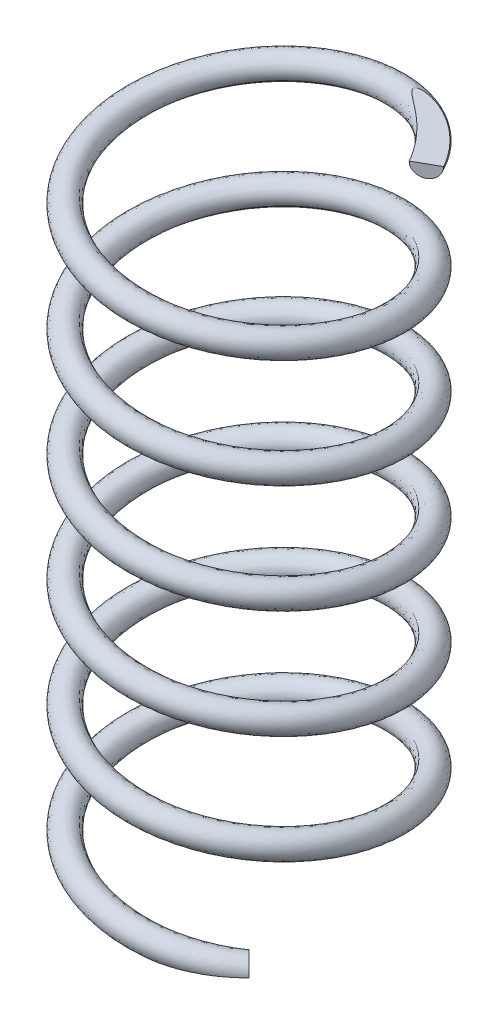
from build123d import *

# Parameters (mm, degrees)
WYCI_GNI_CIE_PO_CIE_CE1_PITCH       = 15
WYCI_GNI_CIE_PO_CIE_CE1_HEIGHT      = 86.9
WYCI_GNI_CIE_PO_CIE_CE1_RADIUS      = 18
WYCI_GNI_CIE_PO_CIE_CE1_START_ANGLE = 45
SZKIC3_R                            = 1.75
SZKIC4_W                            = 85.056572459
SZKIC4_H                            = 48.579847932
WYTNIJ_WYCI_GNI_CIE1_DEPTH          = 55
SZKIC5_W                            = 89.93480105
SZKIC5_H                            = 13.509916719
WYTNIJ_WYCI_GNI_CIE2_DEPTH          = 55


with BuildPart() as part:
    # Wyciągnięcie po ścieżce1: sweep along a helix
    with BuildLine() as wyci_gni_cie_po_cie_ce1_path:
        add(Helix(WYCI_GNI_CIE_PO_CIE_CE1_PITCH, WYCI_GNI_CIE_PO_CIE_CE1_HEIGHT, WYCI_GNI_CIE_PO_CIE_CE1_RADIUS, center=(0, 0, 0), direction=(0, 1, 0), lefthand=True, mode=Mode.PRIVATE).rotate(Axis((0, 0, 0), (0, 1, 0)), WYCI_GNI_CIE_PO_CIE_CE1_START_ANGLE))
    # Szkic3 → Wyciągnięcie po ścieżce1 (sweep)
    with BuildSketch(Plane(origin=(0, 0, 0), x_dir=(-0.707106781, 0, -0.707106781), z_dir=(0.707106781, 0, -0.707106781))):
        with Locations((-18, 0)):
            Circle(SZKIC3_R)
    sweep(path=wyci_gni_cie_po_cie_ce1_path.line, is_frenet=True)

    # Szkic4 → Wytnij-wyciągnięcie1 (cut)
    with BuildSketch(Plane(origin=(0, 0, 0), x_dir=(0.871217089, 0, -0.490897936), z_dir=(0.490897936, 0, 0.871217089))):
        with Locations((5.789834219, 111.189175121)):
            Rectangle(SZKIC4_W, SZKIC4_H)
    extrude(amount=-WYTNIJ_WYCI_GNI_CIE1_DEPTH, mode=Mode.SUBTRACT)

    # Szkic5 → Wytnij-wyciągnięcie2 (cut)
    with BuildSketch(Plane(origin=(0, 0, 0), x_dir=(-0.707106781, 0, -0.707106781), z_dir=(0.707106781, 0, -0.707106781))):
        with Locations((0.14545599, -6.75495836)):
            Rectangle(SZKIC5_W, SZKIC5_H)
    extrude(amount=-WYTNIJ_WYCI_GNI_CIE2_DEPTH, mode=Mode.SUBTRACT)


solid = part.part
